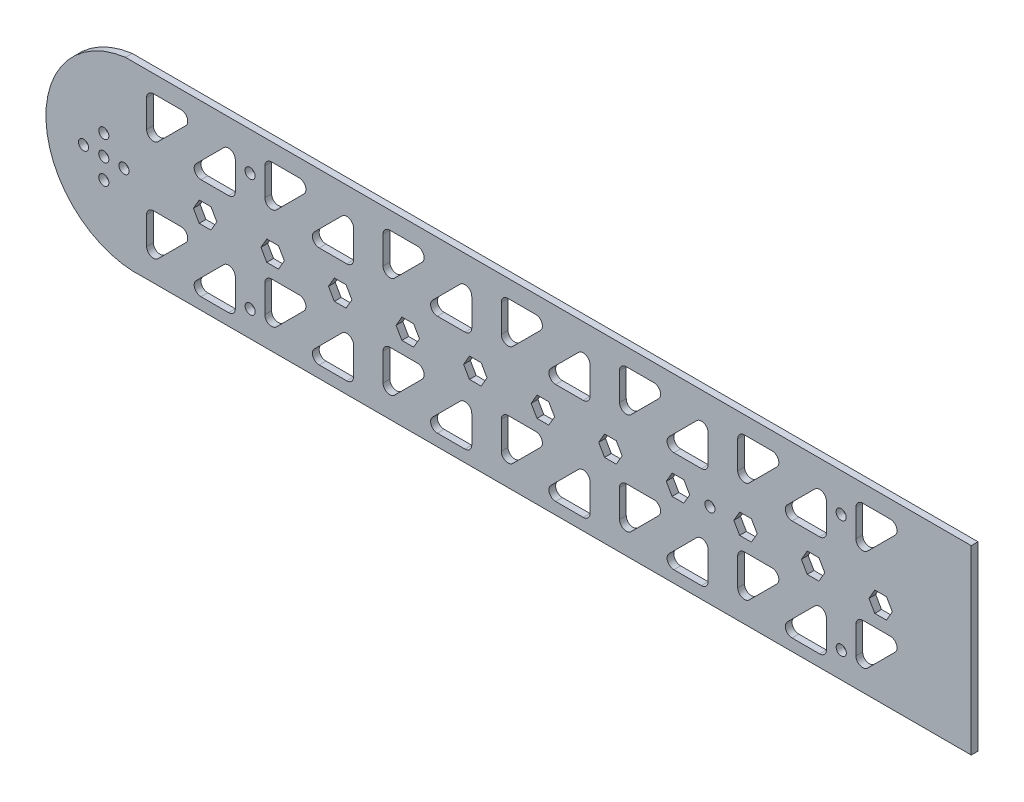
from build123d import *

# Parameters (mm, degrees)
IZIM1_R                     = 1.5
Y_KSEKLIK_EKSTR_ZYON2_DEPTH = 2
IZIM9_R                     = 1.5
KES_EKSTR_ZYON5_DEPTH       = 10
IZIM10_R                    = 1.5
KES_EKSTR_ZYON7_DEPTH       = 10
IZIM11_W                    = 22.917445978
IZIM11_H                    = 53.699619803
KES_EKSTR_ZYON8_DEPTH       = 10
IZIM12_W                    = 2
IZIM12_H                    = 53.699619803
Y_KSEKLIK_EKSTR_ZYON3_DEPTH = 20
KES_EKSTR_ZYON10_DEPTH      = 20
IZIM14_W                    = 20
IZIM14_H                    = 53.699619803
KES_EKSTR_ZYON11_DEPTH      = 10


with BuildPart() as part:
    # Çizim1 → Yükseklik-Ekstrüzyon2 (new body)
    with BuildSketch(Plane.XY):
        with BuildLine():
            ThreePointArc((-123.68208832, 28.6803889), (-147.097650837, -0.85979795), (-118.162671893, -25.019230903))
            Line((-118.162671893, -25.019230903), (122.31562704, -25.019230903))
            Line((122.31562704, -25.019230903), (144.746839173, -25.019230903))
            ThreePointArc((144.746839173, -25.019230903), (146.161052735, -24.433444465), (146.746839173, -23.019230903))
            Line((146.746839173, -23.019230903), (146.746839173, -18.118237576))
            Line((146.746839173, -18.118237576), (127.216282083, -18.118237576))
            Line((127.216282083, -18.118237576), (126.706405407, 21.900803601))
            Line((126.706405407, 21.900803601), (146.706405407, 21.900803601))
            Line((146.706405407, 21.900803601), (146.706405407, 26.6803889))
            ThreePointArc((146.706405407, 26.6803889), (146.120618969, 28.094602463), (144.706405407, 28.6803889))
            Line((144.706405407, 28.6803889), (-123.68208832, 28.6803889))
        make_face()
        with BuildLine():
            Line((-117.432950192, -16.684982837), (-117.432950192, -8.513409962))
            ThreePointArc((-117.432950192, -8.513409962), (-116.847163754, -7.099196399), (-115.432950192, -6.513409962))
            Line((-115.432950192, -6.513409962), (-107.261377316, -6.513409962))
            ThreePointArc((-107.261377316, -6.513409962), (-105.413618251, -7.748043097), (-105.847163754, -9.927623524))
            Line((-105.847163754, -9.927623524), (-114.018736629, -18.099196399))
            ThreePointArc((-114.018736629, -18.099196399), (-116.198317056, -18.532741902), (-117.432950192, -16.684982837))
        make_face(mode=Mode.SUBTRACT)
        with BuildLine():
            Line((-102.756511954, -18.099196399), (-94.584939079, -9.927623524))
            ThreePointArc((-94.584939079, -9.927623524), (-92.405358652, -9.494078021), (-91.170725517, -11.341837086))
            Line((-91.170725517, -11.341837086), (-91.170725517, -19.513409962))
            ThreePointArc((-91.170725517, -19.513409962), (-91.756511954, -20.927623524), (-93.170725517, -21.513409962))
            Line((-93.170725517, -21.513409962), (-101.342298392, -21.513409962))
            ThreePointArc((-101.342298392, -21.513409962), (-103.190057457, -20.278776826), (-102.756511954, -18.099196399))
        make_face(mode=Mode.SUBTRACT)
        with BuildLine():
            Line((-82.432950192, -16.684982837), (-82.432950192, -8.513409962))
            ThreePointArc((-82.432950192, -8.513409962), (-81.847163754, -7.099196399), (-80.432950192, -6.513409962))
            Line((-80.432950192, -6.513409962), (-72.261377316, -6.513409962))
            ThreePointArc((-72.261377316, -6.513409962), (-70.413618251, -7.748043097), (-70.847163754, -9.927623524))
            Line((-70.847163754, -9.927623524), (-79.018736629, -18.099196399))
            ThreePointArc((-79.018736629, -18.099196399), (-81.198317056, -18.532741902), (-82.432950192, -16.684982837))
        make_face(mode=Mode.SUBTRACT)
        with BuildLine():
            Line((-67.756511954, -18.099196399), (-59.584939079, -9.927623524))
            ThreePointArc((-59.584939079, -9.927623524), (-57.405358652, -9.494078021), (-56.170725517, -11.341837086))
            Line((-56.170725517, -11.341837086), (-56.170725517, -19.513409962))
            ThreePointArc((-56.170725517, -19.513409962), (-56.756511954, -20.927623524), (-58.170725517, -21.513409962))
            Line((-58.170725517, -21.513409962), (-66.342298392, -21.513409962))
            ThreePointArc((-66.342298392, -21.513409962), (-68.190057457, -20.278776826), (-67.756511954, -18.099196399))
        make_face(mode=Mode.SUBTRACT)
        with BuildLine():
            Line((-47.432950192, -16.684982837), (-47.432950192, -8.513409962))
            ThreePointArc((-47.432950192, -8.513409962), (-46.847163754, -7.099196399), (-45.432950192, -6.513409962))
            Line((-45.432950192, -6.513409962), (-37.261377316, -6.513409962))
            ThreePointArc((-37.261377316, -6.513409962), (-35.413618251, -7.748043097), (-35.847163754, -9.927623524))
            Line((-35.847163754, -9.927623524), (-44.018736629, -18.099196399))
            ThreePointArc((-44.018736629, -18.099196399), (-46.198317056, -18.532741902), (-47.432950192, -16.684982837))
        make_face(mode=Mode.SUBTRACT)
        with BuildLine():
            Line((-32.756511954, -18.099196399), (-24.584939079, -9.927623524))
            ThreePointArc((-24.584939079, -9.927623524), (-22.405358652, -9.494078021), (-21.170725517, -11.341837086))
            Line((-21.170725517, -11.341837086), (-21.170725517, -19.513409962))
            ThreePointArc((-21.170725517, -19.513409962), (-21.756511954, -20.927623524), (-23.170725517, -21.513409962))
            Line((-23.170725517, -21.513409962), (-31.342298392, -21.513409962))
            ThreePointArc((-31.342298392, -21.513409962), (-33.190057457, -20.278776826), (-32.756511954, -18.099196399))
        make_face(mode=Mode.SUBTRACT)
        with BuildLine():
            Line((-12.432950192, -16.684982837), (-12.432950192, -8.513409962))
            ThreePointArc((-12.432950192, -8.513409962), (-11.847163754, -7.099196399), (-10.432950192, -6.513409962))
            Line((-10.432950192, -6.513409962), (-2.261377316, -6.513409962))
            ThreePointArc((-2.261377316, -6.513409962), (-0.413618251, -7.748043097), (-0.847163754, -9.927623524))
            Line((-0.847163754, -9.927623524), (-9.018736629, -18.099196399))
            ThreePointArc((-9.018736629, -18.099196399), (-11.198317056, -18.532741902), (-12.432950192, -16.684982837))
        make_face(mode=Mode.SUBTRACT)
        Polygon((-96.652716692, 0.01885212), (-98.388672632, -2.978889859), (-101.85277131, -2.974378905), (-103.580914048, 0.027874028), (-101.844958108, 3.025616007), (-98.38085943, 3.021105053), align=None, mode=Mode.SUBTRACT)
        Polygon((-76.652716692, 0.01885212), (-78.388672632, -2.978889859), (-81.85277131, -2.974378905), (-83.580914048, 0.027874028), (-81.844958108, 3.025616007), (-78.38085943, 3.021105053), align=None, mode=Mode.SUBTRACT)
        Polygon((-56.652716692, 0.01885212), (-58.388672632, -2.978889859), (-61.85277131, -2.974378905), (-63.580914048, 0.027874028), (-61.844958108, 3.025616007), (-58.38085943, 3.021105053), align=None, mode=Mode.SUBTRACT)
        Polygon((-36.652716692, 0.01885212), (-38.388672632, -2.978889859), (-41.85277131, -2.974378905), (-43.580914048, 0.027874028), (-41.844958108, 3.025616007), (-38.38085943, 3.021105053), align=None, mode=Mode.SUBTRACT)
        Polygon((-16.652716692, 0.01885212), (-18.388672632, -2.978889859), (-21.85277131, -2.974378905), (-23.580914048, 0.027874028), (-21.844958108, 3.025616007), (-18.38085943, 3.021105053), align=None, mode=Mode.SUBTRACT)
        Polygon((3.347283308, 0.01885212), (1.611327368, -2.978889859), (-1.85277131, -2.974378905), (-3.580914048, 0.027874028), (-1.844958108, 3.025616007), (1.61914057, 3.021105053), align=None, mode=Mode.SUBTRACT)
        with BuildLine():
            Line((2.243488046, -18.099196399), (10.415060921, -9.927623524))
            ThreePointArc((10.415060921, -9.927623524), (12.594641348, -9.494078021), (13.829274483, -11.341837086))
            Line((13.829274483, -11.341837086), (13.829274483, -19.513409962))
            ThreePointArc((13.829274483, -19.513409962), (13.243488046, -20.927623524), (11.829274483, -21.513409962))
            Line((11.829274483, -21.513409962), (3.657701608, -21.513409962))
            ThreePointArc((3.657701608, -21.513409962), (1.809942543, -20.278776826), (2.243488046, -18.099196399))
        make_face(mode=Mode.SUBTRACT)
        with BuildLine():
            Line((22.567049808, -16.684982837), (22.567049808, -8.513409962))
            ThreePointArc((22.567049808, -8.513409962), (23.152836246, -7.099196399), (24.567049808, -6.513409962))
            Line((24.567049808, -6.513409962), (32.738622684, -6.513409962))
            ThreePointArc((32.738622684, -6.513409962), (34.586381749, -7.748043097), (34.152836246, -9.927623524))
            Line((34.152836246, -9.927623524), (25.981263371, -18.099196399))
            ThreePointArc((25.981263371, -18.099196399), (23.801682944, -18.532741902), (22.567049808, -16.684982837))
        make_face(mode=Mode.SUBTRACT)
        with BuildLine():
            Line((37.243488046, -18.099196399), (45.415060921, -9.927623524))
            ThreePointArc((45.415060921, -9.927623524), (47.594641348, -9.494078021), (48.829274483, -11.341837086))
            Line((48.829274483, -11.341837086), (48.829274483, -19.513409962))
            ThreePointArc((48.829274483, -19.513409962), (48.243488046, -20.927623524), (46.829274483, -21.513409962))
            Line((46.829274483, -21.513409962), (38.657701608, -21.513409962))
            ThreePointArc((38.657701608, -21.513409962), (36.809942543, -20.278776826), (37.243488046, -18.099196399))
        make_face(mode=Mode.SUBTRACT)
        with BuildLine():
            Line((57.567049808, -16.684982837), (57.567049808, -8.513409962))
            ThreePointArc((57.567049808, -8.513409962), (58.152836246, -7.099196399), (59.567049808, -6.513409962))
            Line((59.567049808, -6.513409962), (67.738622684, -6.513409962))
            ThreePointArc((67.738622684, -6.513409962), (69.586381749, -7.748043097), (69.152836246, -9.927623524))
            Line((69.152836246, -9.927623524), (60.981263371, -18.099196399))
            ThreePointArc((60.981263371, -18.099196399), (58.801682944, -18.532741902), (57.567049808, -16.684982837))
        make_face(mode=Mode.SUBTRACT)
        with Locations((131.859799091, -22.099196399)):
            Circle(IZIM1_R, mode=Mode.SUBTRACT)
        with Locations((141.859799091, -22.099196399)):
            Circle(IZIM1_R, mode=Mode.SUBTRACT)
        with BuildLine():
            Line((72.243488046, -18.099196399), (80.415060921, -9.927623524))
            ThreePointArc((80.415060921, -9.927623524), (82.594641348, -9.494078021), (83.829274483, -11.341837086))
            Line((83.829274483, -11.341837086), (83.829274483, -19.513409962))
            ThreePointArc((83.829274483, -19.513409962), (83.243488046, -20.927623524), (81.829274483, -21.513409962))
            Line((81.829274483, -21.513409962), (73.657701608, -21.513409962))
            ThreePointArc((73.657701608, -21.513409962), (71.809942543, -20.278776826), (72.243488046, -18.099196399))
        make_face(mode=Mode.SUBTRACT)
        with BuildLine():
            Line((92.567049808, -16.684982837), (92.567049808, -8.513409962))
            ThreePointArc((92.567049808, -8.513409962), (93.152836246, -7.099196399), (94.567049808, -6.513409962))
            Line((94.567049808, -6.513409962), (102.738622684, -6.513409962))
            ThreePointArc((102.738622684, -6.513409962), (104.586381749, -7.748043097), (104.152836246, -9.927623524))
            Line((104.152836246, -9.927623524), (95.981263371, -18.099196399))
            ThreePointArc((95.981263371, -18.099196399), (93.801682944, -18.532741902), (92.567049808, -16.684982837))
        make_face(mode=Mode.SUBTRACT)
        Polygon((23.347283308, 0.01885212), (21.611327368, -2.978889859), (18.14722869, -2.974378905), (16.419085952, 0.027874028), (18.155041892, 3.025616007), (21.61914057, 3.021105053), align=None, mode=Mode.SUBTRACT)
        Polygon((43.347283308, 0.01885212), (41.611327368, -2.978889859), (38.14722869, -2.974378905), (36.419085952, 0.027874028), (38.155041892, 3.025616007), (41.61914057, 3.021105053), align=None, mode=Mode.SUBTRACT)
        Polygon((63.347283308, 0.01885212), (61.611327368, -2.978889859), (58.14722869, -2.974378905), (56.419085952, 0.027874028), (58.155041892, 3.025616007), (61.61914057, 3.021105053), align=None, mode=Mode.SUBTRACT)
        Polygon((83.347283308, 0.01885212), (81.611327368, -2.978889859), (78.14722869, -2.974378905), (76.419085952, 0.027874028), (78.155041892, 3.025616007), (81.61914057, 3.021105053), align=None, mode=Mode.SUBTRACT)
        Polygon((103.347283308, 0.01885212), (101.611327368, -2.978889859), (98.14722869, -2.974378905), (96.419085952, 0.027874028), (98.155041892, 3.025616007), (101.61914057, 3.021105053), align=None, mode=Mode.SUBTRACT)
        with BuildLine():
            Line((-102.756511954, 11.900803601), (-94.584939079, 20.072376476))
            ThreePointArc((-94.584939079, 20.072376476), (-92.405358652, 20.505921979), (-91.170725517, 18.658162914))
            Line((-91.170725517, 18.658162914), (-91.170725517, 10.486590038))
            ThreePointArc((-91.170725517, 10.486590038), (-91.756511954, 9.072376476), (-93.170725517, 8.486590038))
            Line((-93.170725517, 8.486590038), (-101.342298392, 8.486590038))
            ThreePointArc((-101.342298392, 8.486590038), (-103.190057457, 9.721223174), (-102.756511954, 11.900803601))
        make_face(mode=Mode.SUBTRACT)
        with BuildLine():
            Line((-67.756511954, 11.900803601), (-59.584939079, 20.072376476))
            ThreePointArc((-59.584939079, 20.072376476), (-57.405358652, 20.505921979), (-56.170725517, 18.658162914))
            Line((-56.170725517, 18.658162914), (-56.170725517, 10.486590038))
            ThreePointArc((-56.170725517, 10.486590038), (-56.756511954, 9.072376476), (-58.170725517, 8.486590038))
            Line((-58.170725517, 8.486590038), (-66.342298392, 8.486590038))
            ThreePointArc((-66.342298392, 8.486590038), (-68.190057457, 9.721223174), (-67.756511954, 11.900803601))
        make_face(mode=Mode.SUBTRACT)
        with BuildLine():
            Line((-32.756511954, 11.900803601), (-24.584939079, 20.072376476))
            ThreePointArc((-24.584939079, 20.072376476), (-22.405358652, 20.505921979), (-21.170725517, 18.658162914))
            Line((-21.170725517, 18.658162914), (-21.170725517, 10.486590038))
            ThreePointArc((-21.170725517, 10.486590038), (-21.756511954, 9.072376476), (-23.170725517, 8.486590038))
            Line((-23.170725517, 8.486590038), (-31.342298392, 8.486590038))
            ThreePointArc((-31.342298392, 8.486590038), (-33.190057457, 9.721223174), (-32.756511954, 11.900803601))
        make_face(mode=Mode.SUBTRACT)
        with BuildLine():
            Line((-117.432950192, 13.315017163), (-117.432950192, 21.486590038))
            ThreePointArc((-117.432950192, 21.486590038), (-116.847163754, 22.900803601), (-115.432950192, 23.486590038))
            Line((-115.432950192, 23.486590038), (-107.261377316, 23.486590038))
            ThreePointArc((-107.261377316, 23.486590038), (-105.413618251, 22.251956903), (-105.847163754, 20.072376476))
            Line((-105.847163754, 20.072376476), (-114.018736629, 11.900803601))
            ThreePointArc((-114.018736629, 11.900803601), (-116.198317056, 11.467258098), (-117.432950192, 13.315017163))
        make_face(mode=Mode.SUBTRACT)
        with BuildLine():
            Line((-82.432950192, 13.315017163), (-82.432950192, 21.486590038))
            ThreePointArc((-82.432950192, 21.486590038), (-81.847163754, 22.900803601), (-80.432950192, 23.486590038))
            Line((-80.432950192, 23.486590038), (-72.261377316, 23.486590038))
            ThreePointArc((-72.261377316, 23.486590038), (-70.413618251, 22.251956903), (-70.847163754, 20.072376476))
            Line((-70.847163754, 20.072376476), (-79.018736629, 11.900803601))
            ThreePointArc((-79.018736629, 11.900803601), (-81.198317056, 11.467258098), (-82.432950192, 13.315017163))
        make_face(mode=Mode.SUBTRACT)
        with BuildLine():
            Line((-47.432950192, 13.315017163), (-47.432950192, 21.486590038))
            ThreePointArc((-47.432950192, 21.486590038), (-46.847163754, 22.900803601), (-45.432950192, 23.486590038))
            Line((-45.432950192, 23.486590038), (-37.261377316, 23.486590038))
            ThreePointArc((-37.261377316, 23.486590038), (-35.413618251, 22.251956903), (-35.847163754, 20.072376476))
            Line((-35.847163754, 20.072376476), (-44.018736629, 11.900803601))
            ThreePointArc((-44.018736629, 11.900803601), (-46.198317056, 11.467258098), (-47.432950192, 13.315017163))
        make_face(mode=Mode.SUBTRACT)
        with BuildLine():
            Line((-12.432950192, 13.315017163), (-12.432950192, 21.486590038))
            ThreePointArc((-12.432950192, 21.486590038), (-11.847163754, 22.900803601), (-10.432950192, 23.486590038))
            Line((-10.432950192, 23.486590038), (-2.261377316, 23.486590038))
            ThreePointArc((-2.261377316, 23.486590038), (-0.413618251, 22.251956903), (-0.847163754, 20.072376476))
            Line((-0.847163754, 20.072376476), (-9.018736629, 11.900803601))
            ThreePointArc((-9.018736629, 11.900803601), (-11.198317056, 11.467258098), (-12.432950192, 13.315017163))
        make_face(mode=Mode.SUBTRACT)
        with BuildLine():
            Line((2.243488046, 11.900803601), (10.415060921, 20.072376476))
            ThreePointArc((10.415060921, 20.072376476), (12.594641348, 20.505921979), (13.829274483, 18.658162914))
            Line((13.829274483, 18.658162914), (13.829274483, 10.486590038))
            ThreePointArc((13.829274483, 10.486590038), (13.243488046, 9.072376476), (11.829274483, 8.486590038))
            Line((11.829274483, 8.486590038), (3.657701608, 8.486590038))
            ThreePointArc((3.657701608, 8.486590038), (1.809942543, 9.721223174), (2.243488046, 11.900803601))
        make_face(mode=Mode.SUBTRACT)
        with BuildLine():
            Line((37.243488046, 11.900803601), (45.415060921, 20.072376476))
            ThreePointArc((45.415060921, 20.072376476), (47.594641348, 20.505921979), (48.829274483, 18.658162914))
            Line((48.829274483, 18.658162914), (48.829274483, 10.486590038))
            ThreePointArc((48.829274483, 10.486590038), (48.243488046, 9.072376476), (46.829274483, 8.486590038))
            Line((46.829274483, 8.486590038), (38.657701608, 8.486590038))
            ThreePointArc((38.657701608, 8.486590038), (36.809942543, 9.721223174), (37.243488046, 11.900803601))
        make_face(mode=Mode.SUBTRACT)
        with BuildLine():
            Line((72.243488046, 11.900803601), (80.415060921, 20.072376476))
            ThreePointArc((80.415060921, 20.072376476), (82.594641348, 20.505921979), (83.829274483, 18.658162914))
            Line((83.829274483, 18.658162914), (83.829274483, 10.486590038))
            ThreePointArc((83.829274483, 10.486590038), (83.243488046, 9.072376476), (81.829274483, 8.486590038))
            Line((81.829274483, 8.486590038), (73.657701608, 8.486590038))
            ThreePointArc((73.657701608, 8.486590038), (71.809942543, 9.721223174), (72.243488046, 11.900803601))
        make_face(mode=Mode.SUBTRACT)
        with BuildLine():
            Line((22.567049808, 13.315017163), (22.567049808, 21.486590038))
            ThreePointArc((22.567049808, 21.486590038), (23.152836246, 22.900803601), (24.567049808, 23.486590038))
            Line((24.567049808, 23.486590038), (32.738622684, 23.486590038))
            ThreePointArc((32.738622684, 23.486590038), (34.586381749, 22.251956903), (34.152836246, 20.072376476))
            Line((34.152836246, 20.072376476), (25.981263371, 11.900803601))
            ThreePointArc((25.981263371, 11.900803601), (23.801682944, 11.467258098), (22.567049808, 13.315017163))
        make_face(mode=Mode.SUBTRACT)
        with BuildLine():
            Line((57.567049808, 13.315017163), (57.567049808, 21.486590038))
            ThreePointArc((57.567049808, 21.486590038), (58.152836246, 22.900803601), (59.567049808, 23.486590038))
            Line((59.567049808, 23.486590038), (67.738622684, 23.486590038))
            ThreePointArc((67.738622684, 23.486590038), (69.586381749, 22.251956903), (69.152836246, 20.072376476))
            Line((69.152836246, 20.072376476), (60.981263371, 11.900803601))
            ThreePointArc((60.981263371, 11.900803601), (58.801682944, 11.467258098), (57.567049808, 13.315017163))
        make_face(mode=Mode.SUBTRACT)
        with BuildLine():
            Line((92.567049808, 13.315017163), (92.567049808, 21.486590038))
            ThreePointArc((92.567049808, 21.486590038), (93.152836246, 22.900803601), (94.567049808, 23.486590038))
            Line((94.567049808, 23.486590038), (102.738622684, 23.486590038))
            ThreePointArc((102.738622684, 23.486590038), (104.586381749, 22.251956903), (104.152836246, 20.072376476))
            Line((104.152836246, 20.072376476), (95.981263371, 11.900803601))
            ThreePointArc((95.981263371, 11.900803601), (93.801682944, 11.467258098), (92.567049808, 13.315017163))
        make_face(mode=Mode.SUBTRACT)
        with Locations((131.859799091, 25.900803601)):
            Circle(IZIM1_R, mode=Mode.SUBTRACT)
        with Locations((141.859799091, 25.900803601)):
            Circle(IZIM1_R, mode=Mode.SUBTRACT)
        with Locations((-130.106258095, 6.023363074)):
            Circle(IZIM1_R, mode=Mode.SUBTRACT)
        with Locations((-130.106258095, -5.976636926)):
            Circle(IZIM1_R, mode=Mode.SUBTRACT)
        with Locations((-136.106258095, 0.023363074)):
            Circle(IZIM1_R, mode=Mode.SUBTRACT)
        with Locations((-130.106258095, 0.023363074)):
            Circle(IZIM1_R, mode=Mode.SUBTRACT)
        with Locations((-124.106258095, 0.023363074)):
            Circle(IZIM1_R, mode=Mode.SUBTRACT)
    extrude(amount=Y_KSEKLIK_EKSTR_ZYON2_DEPTH)

    # Çizim9 → Kes-Ekstrüzyon5 (cut)
    with BuildSketch(Plane(origin=(0, 0, 0), x_dir=(-1, 0, 0), z_dir=(0, 0, -1))):
        with Locations((-88.198162146, 17.400803601)):
            Circle(IZIM9_R)
        with Locations((-88.222150893, -17.356386837)):
            Circle(IZIM9_R)
        with Locations((86.801837854, 17.400803601)):
            Circle(IZIM9_R)
        with Locations((86.777849107, -17.356386837)):
            Circle(IZIM9_R)
    extrude(amount=-KES_EKSTR_ZYON5_DEPTH, mode=Mode.SUBTRACT)

    # Çizim10 → Kes-Ekstrüzyon7 (cut)
    with BuildSketch(Plane.XY.offset(2)):
        with Locations((49.347283308, 0)):
            Circle(IZIM10_R)
    extrude(amount=-KES_EKSTR_ZYON7_DEPTH, mode=Mode.SUBTRACT)

    # Çizim11 → Kes-Ekstrüzyon8 (cut)
    with BuildSketch(Plane.XY.offset(2)):
        with Locations((138.165128396, 1.830578999)):
            Rectangle(IZIM11_W, IZIM11_H)
    extrude(amount=-KES_EKSTR_ZYON8_DEPTH, mode=Mode.SUBTRACT)

    # Çizim12 → Yükseklik-Ekstrüzyon3 (add)
    with BuildSketch(Plane.XY.offset(2)):
        with Locations((125.706405407, 1.830578999)):
            Rectangle(IZIM12_W, IZIM12_H)
    extrude(amount=Y_KSEKLIK_EKSTR_ZYON3_DEPTH)

    # Çizim13 → Kes-Ekstrüzyon10 (cut)
    with BuildSketch(Plane(origin=(126.706405407, 0, 0), x_dir=(0, 0, -1), z_dir=(1, 0, 0))):
        Polygon((-22, 2.407950672), (-22, -17.592049328), (-2, -17.592049328), (-2, 2.407950672), (-2, 22.407950672), (-22, 22.407950672), align=None)
    extrude(amount=-KES_EKSTR_ZYON10_DEPTH, mode=Mode.SUBTRACT)

    # Çizim14 → Kes-Ekstrüzyon11 (cut)
    with BuildSketch(Plane.ZY.offset(-124.706405407)):
        with Locations((12, 1.830578999)):
            Rectangle(IZIM14_W, IZIM14_H)
    extrude(amount=-KES_EKSTR_ZYON11_DEPTH, mode=Mode.SUBTRACT)


solid = part.part
